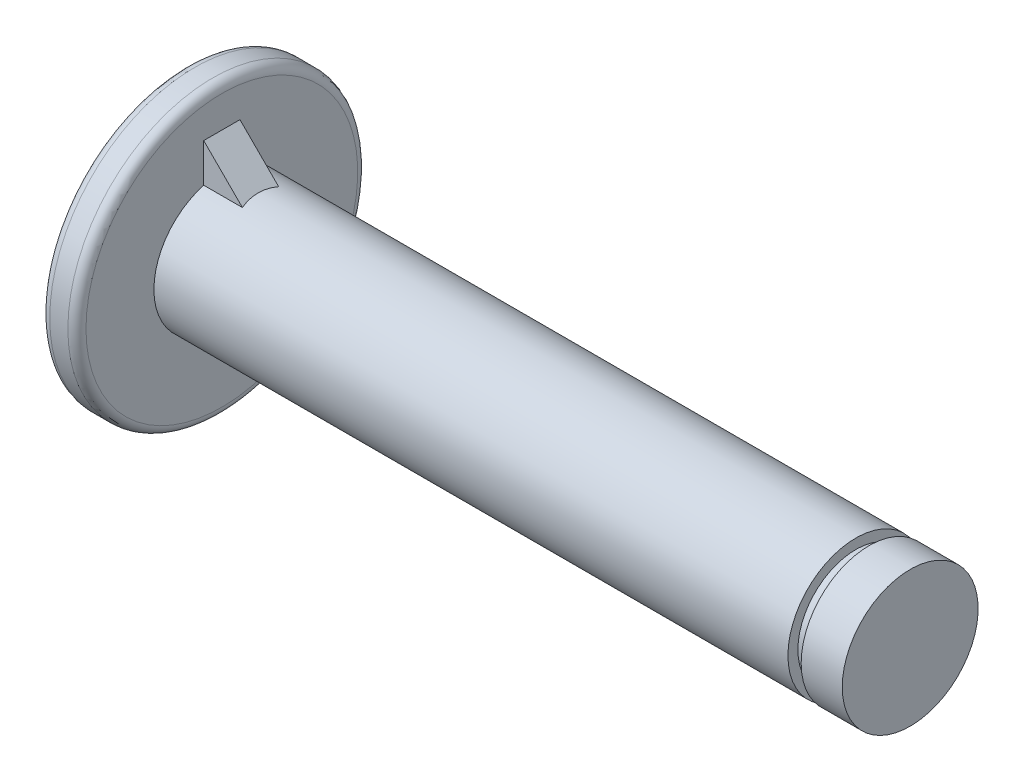
from build123d import *

# Parameters (mm, degrees)
FILLET1_R      = 0.5
RIB1_REACH     = 43.569
SKETCH2_WALL_W = 87.966865888
SKETCH2_WALL_H = 2


with BuildPart() as part:
    # Sketch1 → Revolve1 (revolve)
    with BuildSketch(Plane.XY, mode=Mode.PRIVATE) as revolve1_sk:
        Polygon((0, 8), (0, 0), (40, 0), (40, 3.75), (37.73, 3.75), (37.73, 3.2), (37, 3.2), (37, 3.75), (2, 3.75), (2, 8), align=None)
    revolve(revolve1_sk.sketch.rotate(Axis((0, 0, 0), (1, 0, 0)), 90), axis=Axis((0, 0, 0), (1, 0, 0)))

    # Fillet1
    fillet1_edges = [part.edges().sort_by_distance(p)[0] for p in [
        (0, 0, -8),
        (2, 0, -8),
    ]]
    fillet(fillet1_edges, radius=FILLET1_R)

    # Sketch2 wall → Rib1 (add, up to next)
    with BuildSketch(Plane(origin=(3, 4.75, 0), x_dir=(-0.707106781187, 0.707106781187, 0), z_dir=(-0.707106781187, -0.707106781187, 0)), mode=Mode.PRIVATE) as rib1_sk1:
        Rectangle(SKETCH2_WALL_W, SKETCH2_WALL_H)
    rib1_tool1 = extrude(rib1_sk1.sketch, amount=RIB1_REACH, mode=Mode.PRIVATE) - part.part
    add(rib1_tool1.solids().sort_by_distance((3, 4.75, 0))[0])


solid = part.part
